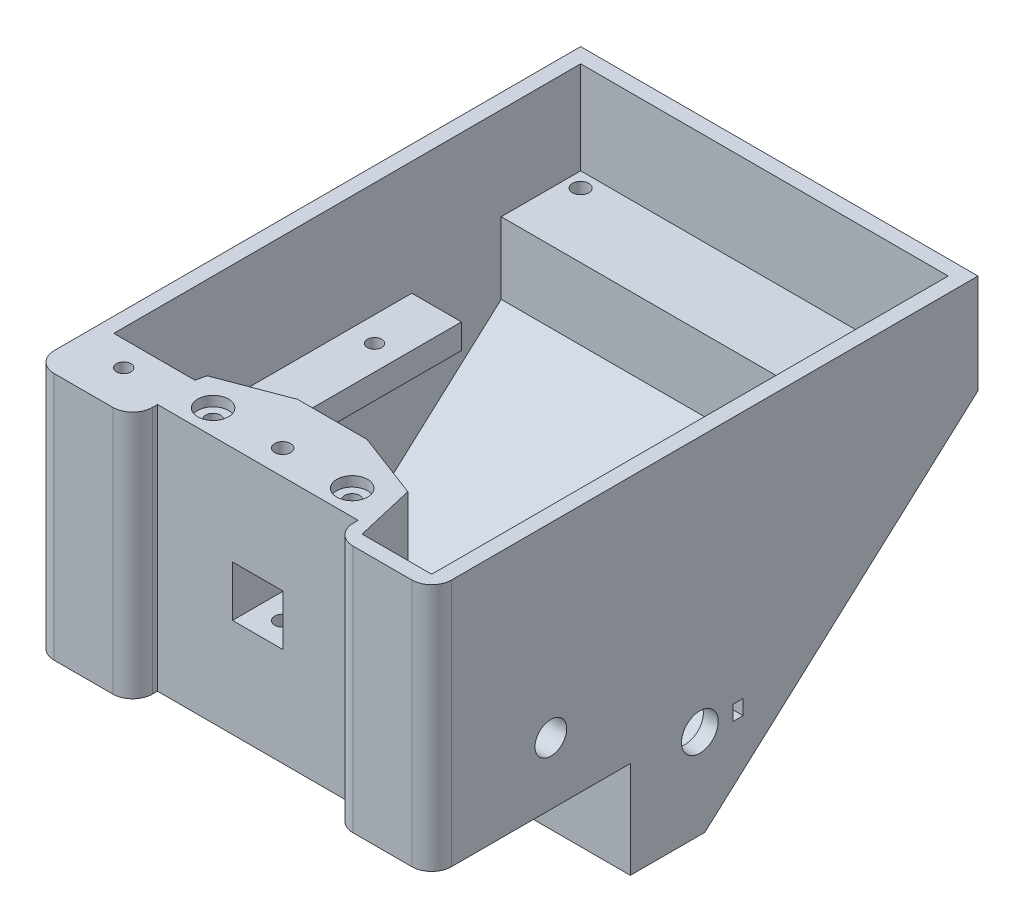
from build123d import *

# Parameters (mm, degrees)
BOSS_EXTRUDE1_DEPTH = 80
SHELL1_T            = -3
SKETCH3_W           = 46
SKETCH3_H           = 47
BOSS_EXTRUDE2_DEPTH = 17
SKETCH4_W           = 10.2
SKETCH4_H           = 10.2
CUT_EXTRUDE1_DEPTH  = 20
SKETCH6_W           = 15
SKETCH6_H           = 12.8
CUT_EXTRUDE2_DEPTH  = 3
SKETCH7_W           = 40.4
SKETCH7_H           = 50
CUT_EXTRUDE3_DEPTH  = 5
FILLET1_R           = 4
CUT_EXTRUDE7_DEPTH  = 47
SKETCH13_R          = 1.5
CUT_EXTRUDE8_DEPTH  = 25
SKETCH14_R          = 3.1
CUT_EXTRUDE9_DEPTH  = 2
SKETCH17_W          = 45
SKETCH17_H          = 5
BOSS_EXTRUDE5_DEPTH = 74
CUT_EXTRUDE10_REACH = 48.51
SKETCH18_W          = 54
SKETCH18_H          = 45
CUT_EXTRUDE11_REACH = 48.51
SKETCH19_R          = 1.45
BOSS_EXTRUDE6_DEPTH = 47
SKETCH22_R          = 1.45
CUT_EXTRUDE12_DEPTH = 70.509632224
CUT_EXTRUDE13_REACH = 82
SKETCH24_R          = 3.7
SKETCH24_W          = 2
SKETCH24_H          = 3
BOSS_EXTRUDE7_DEPTH = 74
SKETCH27_R          = 1.65
CUT_EXTRUDE14_DEPTH = 10
CUT_EXTRUDE15_START = -3
CUT_EXTRUDE15_DEPTH = 32
CUT_EXTRUDE16_DEPTH = 30
BOSS_EXTRUDE8_DEPTH = 20
SKETCH31_R          = 1.5
CUT_EXTRUDE17_DEPTH = 43.509632224
CUT_EXTRUDE18_DEPTH = 15
CUT_EXTRUDE19_REACH = 48.51
SKETCH33_W          = 10
SKETCH33_H          = 5
SKETCH34_R          = 1.6
CUT_EXTRUDE20_DEPTH = 70.509632224
CUT_EXTRUDE22_DEPTH = 14
CUT_EXTRUDE23_REACH = 82
SKETCH37_R          = 3.2
SKETCH38_W          = 10
SKETCH38_H          = 18.980735551
SKETCH38_R          = 3.2
BOSS_EXTRUDE9_DEPTH = 3


with BuildPart() as part:
    # Sketch2 → Boss-Extrude1 (new body)
    with BuildSketch(Plane(origin=(0, 0, 0), x_dir=(0, 0, -1), z_dir=(1, 0, 0))):
        Polygon((-27.320490368, 20.998248687), (-27.320490368, -29.001751313), (12.679509632, -29.001751313), (12.679509632, -48.511383538), (27.679509632, -48.511383538), (82.679509632, 0.998248687), (82.679509632, 20.998248687), align=None)
    extrude(amount=BOSS_EXTRUDE1_DEPTH)

    # Shell1
    shell1_openings = [part.faces().sort_by_distance(p)[0] for p in [
        (40, 20.998248687, -27.679509632),
    ]]
    offset(amount=SHELL1_T, openings=shell1_openings, kind=Kind.INTERSECTION)

    # Sketch3 → Boss-Extrude2 (add)
    with BuildSketch(Plane(origin=(0, 0, 24.320490368), x_dir=(-1, 0, 0), z_dir=(0, 0, -1))):
        with Locations((-40, -2.501751313)):
            Rectangle(SKETCH3_W, SKETCH3_H)
    extrude(amount=BOSS_EXTRUDE2_DEPTH)

    # Sketch4 → Cut-Extrude1 (cut)
    with BuildSketch(Plane.XY.offset(27.320490368)):
        with Locations((40, -4.001751313)):
            Rectangle(SKETCH4_W, SKETCH4_H)
    extrude(amount=-CUT_EXTRUDE1_DEPTH, mode=Mode.SUBTRACT)

    # Sketch6 → Cut-Extrude2 (cut)
    with BuildSketch(Plane.XZ.offset(29.001751313)):
        with Locations((40, 0.920490368)):
            Rectangle(SKETCH6_W, SKETCH6_H)
    extrude(amount=-CUT_EXTRUDE2_DEPTH, mode=Mode.SUBTRACT)

    # Sketch7 → Cut-Extrude3 (cut)
    with BuildSketch(Plane.XY.offset(27.320490368)):
        with Locations((40, -4.001751313)):
            Rectangle(SKETCH7_W, SKETCH7_H)
    extrude(amount=-CUT_EXTRUDE3_DEPTH, mode=Mode.SUBTRACT)

    # Fillet1
    fillet1_edges = [part.edges().sort_by_distance(p)[0] for p in [
        (80, -4.001751313, 27.320490368),
        (19.8, -4.001751313, 27.320490368),
        (0, -4.001751313, 27.320490368),
        (60.2, -4.001751313, 27.320490368),
    ]]
    fillet(fillet1_edges, radius=FILLET1_R)

    # Sketch12 → Cut-Extrude7 (cut)
    with BuildSketch(Plane(origin=(0, 20.998248687, 0), x_dir=(1, 0, 0), z_dir=(0, 1, 0))):
        Polygon((33, -7.320490368), (19.8, -12.320490368), (17, -24.320490368), (17, -7.320490368), align=None)
        Polygon((47, -7.320490368), (63, -7.320490368), (63, -24.320490368), (60.2, -12.320490368), align=None)
    extrude(amount=-CUT_EXTRUDE7_DEPTH, mode=Mode.SUBTRACT)

    # Sketch13 → Cut-Extrude8 (cut)
    with BuildSketch(Plane(origin=(0, 20.998248687, 0), x_dir=(1, 0, 0), z_dir=(0, 1, 0))):
        with Locations(Location((26, -17.320490368, 0), (0, 0, 270))):  # turned: the seam where the file's is
            Circle(SKETCH13_R)
        with Locations(Location((54, -17.320490368, 0), (0, 0, 270))):  # turned: the seam where the file's is
            Circle(SKETCH13_R)
    extrude(amount=-CUT_EXTRUDE8_DEPTH, mode=Mode.SUBTRACT)

    # Sketch14 → Cut-Extrude9 (cut)
    with BuildSketch(Plane(origin=(0, 20.998248687, 0), x_dir=(1, 0, 0), z_dir=(0, 1, 0))):
        with Locations(Location((26, -17.320490368, 0), (0, 0, 270))):  # turned: the seam where the file's is
            Circle(SKETCH14_R)
        with Locations(Location((54, -17.320490368, 0), (0, 0, 270))):  # turned: the seam where the file's is
            Circle(SKETCH14_R)
    extrude(amount=-CUT_EXTRUDE9_DEPTH, mode=Mode.SUBTRACT)

    # Sketch17 → Boss-Extrude5 (add)
    with BuildSketch(Plane.ZY.offset(-77)):
        with Locations((-23.179509632, -4.501751313)):
            Rectangle(SKETCH17_W, SKETCH17_H)
    extrude(amount=BOSS_EXTRUDE5_DEPTH)

    # Sketch18 → Cut-Extrude10 (cut, up to next)
    with BuildSketch(Plane(origin=(0, -2.001751313, 0), x_dir=(1, 0, 0), z_dir=(0, 1, 0)), mode=Mode.PRIVATE) as cut_extrude10_sk1:
        with Locations((40, 23.179509632)):
            Rectangle(SKETCH18_W, SKETCH18_H)
    cut_extrude10_tool1 = extrude(cut_extrude10_sk1.sketch, amount=-CUT_EXTRUDE10_REACH, mode=Mode.PRIVATE) & part.part
    add(cut_extrude10_tool1.solids().sort_by_distance((40, -2.001751, -23.17951))[0], mode=Mode.SUBTRACT)

    # Sketch19 → Cut-Extrude11 (cut, up to next)
    with BuildSketch(Plane(origin=(0, -2.001751313, 0), x_dir=(1, 0, 0), z_dir=(0, 1, 0)), mode=Mode.PRIVATE) as cut_extrude11_sk1:
        with Locations(Location((72, 37.179509632, 0), (0, 0, 270))):  # turned: the seam where the file's is
            Circle(SKETCH19_R)
    cut_extrude11_tool1 = extrude(cut_extrude11_sk1.sketch, amount=-CUT_EXTRUDE11_REACH, mode=Mode.PRIVATE) & part.part
    add(cut_extrude11_tool1.solids().sort_by_distance((72, -2.001751, -37.17951))[0], mode=Mode.SUBTRACT)
    # Sketch19 → Cut-Extrude11 (cut, up to next)
    with BuildSketch(Plane(origin=(0, -2.001751313, 0), x_dir=(1, 0, 0), z_dir=(0, 1, 0)), mode=Mode.PRIVATE) as cut_extrude11_sk2:
        with Locations(Location((72, 6.179509632, 0), (0, 0, 270))):  # turned: the seam where the file's is
            Circle(SKETCH19_R)
    cut_extrude11_tool2 = extrude(cut_extrude11_sk2.sketch, amount=-CUT_EXTRUDE11_REACH, mode=Mode.PRIVATE) & part.part
    add(cut_extrude11_tool2.solids().sort_by_distance((72, -2.001751, -6.17951))[0], mode=Mode.SUBTRACT)
    # Sketch19 → Cut-Extrude11 (cut, up to next)
    with BuildSketch(Plane(origin=(0, -2.001751313, 0), x_dir=(1, 0, 0), z_dir=(0, 1, 0)), mode=Mode.PRIVATE) as cut_extrude11_sk3:
        with Locations(Location((8, 33.179509632, 0), (0, 0, 270))):  # turned: the seam where the file's is
            Circle(SKETCH19_R)
    cut_extrude11_tool3 = extrude(cut_extrude11_sk3.sketch, amount=-CUT_EXTRUDE11_REACH, mode=Mode.PRIVATE) & part.part
    add(cut_extrude11_tool3.solids().sort_by_distance((8, -2.001751, -33.17951))[0], mode=Mode.SUBTRACT)
    # Sketch19 → Cut-Extrude11 (cut, up to next)
    with BuildSketch(Plane(origin=(0, -2.001751313, 0), x_dir=(1, 0, 0), z_dir=(0, 1, 0)), mode=Mode.PRIVATE) as cut_extrude11_sk4:
        with Locations(Location((8, 6.179509632, 0), (0, 0, 270))):  # turned: the seam where the file's is
            Circle(SKETCH19_R)
    cut_extrude11_tool4 = extrude(cut_extrude11_sk4.sketch, amount=-CUT_EXTRUDE11_REACH, mode=Mode.PRIVATE) & part.part
    add(cut_extrude11_tool4.solids().sort_by_distance((8, -2.001751, -6.17951))[0], mode=Mode.SUBTRACT)

    # Sketch21 → Boss-Extrude6 (add)
    with BuildSketch(Plane(origin=(0, -26.001751313, 0), x_dir=(1, 0, 0), z_dir=(0, 1, 0))):
        Polygon((3, -24.320490368), (3, -14.320490368), (19.333333333, -14.320490368), (17, -24.320490368), align=None)
    extrude(amount=BOSS_EXTRUDE6_DEPTH)

    # Sketch22 → Cut-Extrude12 (cut, through all)
    with BuildSketch(Plane(origin=(0, 20.998248687, 0), x_dir=(1, 0, 0), z_dir=(0, 1, 0))):
        with Locations(Location((10, -19.320490368, 0), (0, 0, 270))):  # turned: the seam where the file's is
            Circle(SKETCH22_R)
    extrude(amount=-CUT_EXTRUDE12_DEPTH, mode=Mode.SUBTRACT)

    # Sketch24 → Cut-Extrude13 (cut, up to next)
    with BuildSketch(Plane(origin=(80, 0, 0), x_dir=(0, 0, -1), z_dir=(1, 0, 0)), mode=Mode.PRIVATE) as cut_extrude13_sk1:
        with Locations((26.679509632, -30.511383538)):
            Circle(SKETCH24_R)
    cut_extrude13_tool1 = extrude(cut_extrude13_sk1.sketch, amount=-CUT_EXTRUDE13_REACH, mode=Mode.PRIVATE) & part.part
    add(cut_extrude13_tool1.solids().sort_by_distance((80, -30.511384, -26.67951))[0], mode=Mode.SUBTRACT)
    # Sketch24 → Cut-Extrude13 (cut, up to next)
    with BuildSketch(Plane(origin=(80, 0, 0), x_dir=(0, 0, -1), z_dir=(1, 0, 0)), mode=Mode.PRIVATE) as cut_extrude13_sk2:
        with Locations((34.379509632, -30.511383538)):
            Rectangle(SKETCH24_W, SKETCH24_H)
    cut_extrude13_tool2 = extrude(cut_extrude13_sk2.sketch, amount=-CUT_EXTRUDE13_REACH, mode=Mode.PRIVATE) & part.part
    add(cut_extrude13_tool2.solids().sort_by_distance((80, -30.511384, -34.37951))[0], mode=Mode.SUBTRACT)

    # Sketch26 → Boss-Extrude7 (add)
    with BuildSketch(Plane(origin=(3, 0, 0), x_dir=(0, 0, -1), z_dir=(1, 0, 0))):
        Polygon((79.679509632, 2.334161996), (63.679509632, 2.334161996), (63.679509632, -12.068640106), align=None)
    extrude(amount=BOSS_EXTRUDE7_DEPTH)

    # Sketch27 → Cut-Extrude14 (cut)
    with BuildSketch(Plane(origin=(0, 2.334161996, 0), x_dir=(1, 0, 0), z_dir=(0, 1, 0))):
        with Locations(Location((6, 76.679509632, 0), (0, 0, 270))):  # turned: the seam where the file's is
            Circle(SKETCH27_R)
        with Locations(Location((74, 76.679509632, 0), (0, 0, 270))):  # turned: the seam where the file's is
            Circle(SKETCH27_R)
    extrude(amount=-CUT_EXTRUDE14_DEPTH, mode=Mode.SUBTRACT)

    # Sketch28 → Cut-Extrude15 (cut)
    with BuildSketch(Plane(origin=(0, 2.334161996, 0), x_dir=(1, 0, 0), z_dir=(0, 1, 0)).offset(CUT_EXTRUDE15_START)):
        Polygon((74, 79.929509632), (71.185417438, 78.304509632), (71.185417438, 75.054509632), (74, 73.429509632), (76.814582562, 75.054509632), (76.814582562, 78.304509632), align=None)
        Polygon((6, 73.429509632), (8.814582562, 75.054509632), (8.814582562, 78.304509632), (6, 79.929509632), (3.185417438, 78.304509632), (3.185417438, 75.054509632), align=None)
    extrude(amount=-CUT_EXTRUDE15_DEPTH, mode=Mode.SUBTRACT)

    # Sketch29 → Cut-Extrude16 (cut)
    with BuildSketch(Plane.XZ.offset(29.001751313)):
        Polygon((7.185417438, 17.695490368), (10, 16.070490368), (12.814582562, 17.695490368), (12.814582562, 20.945490368), (10, 22.570490368), (7.185417438, 20.945490368), align=None)
    extrude(amount=-CUT_EXTRUDE16_DEPTH, mode=Mode.SUBTRACT)

    # Sketch30 → Boss-Extrude8 (add)
    with BuildSketch(Plane(origin=(0, -26.001751313, 0), x_dir=(1, 0, 0), z_dir=(0, 1, 0))):
        Polygon((77, -24.320490368), (63, -24.320490368), (60.2, -12.320490368), (77, -12.320490368), align=None)
    extrude(amount=BOSS_EXTRUDE8_DEPTH)

    # Sketch31 → Cut-Extrude17 (cut, through all)
    with BuildSketch(Plane(origin=(0, -6.001751313, 0), x_dir=(1, 0, 0), z_dir=(0, 1, 0))):
        with Locations(Location((72, -21.320490368, 0), (0, 0, 270))):  # turned: the seam where the file's is
            Circle(SKETCH31_R)
    extrude(amount=-CUT_EXTRUDE17_DEPTH, mode=Mode.SUBTRACT)

    # Sketch32 → Cut-Extrude18 (cut)
    with BuildSketch(Plane.XZ.offset(29.001751313)):
        Polygon((72, 24.570490368), (69.185417438, 22.945490368), (69.185417438, 19.695490368), (72, 18.070490368), (74.814582562, 19.695490368), (74.814582562, 22.945490368), align=None)
    extrude(amount=-CUT_EXTRUDE18_DEPTH, mode=Mode.SUBTRACT)

    # Sketch33 → Cut-Extrude19 (cut, up to next)
    with BuildSketch(Plane(origin=(0, -2.001751313, 0), x_dir=(1, 0, 0), z_dir=(0, 1, 0)), mode=Mode.PRIVATE) as cut_extrude19_sk1:
        with Locations((72, 43.179509632)):
            Rectangle(SKETCH33_W, SKETCH33_H)
    cut_extrude19_tool1 = extrude(cut_extrude19_sk1.sketch, amount=-CUT_EXTRUDE19_REACH, mode=Mode.PRIVATE) & part.part
    add(cut_extrude19_tool1.solids().sort_by_distance((72, -2.001751, -43.17951))[0], mode=Mode.SUBTRACT)

    # Sketch34 → Cut-Extrude20 (cut, through all)
    with BuildSketch(Plane(origin=(0, 20.998248687, 0), x_dir=(1, 0, 0), z_dir=(0, 1, 0))):
        with Locations(Location((40, -17.320490368, 0), (0, 0, 270))):  # turned: the seam where the file's is
            Circle(SKETCH34_R)
    extrude(amount=-CUT_EXTRUDE20_DEPTH, mode=Mode.SUBTRACT)

    # Sketch36 → Cut-Extrude22 (cut)
    with BuildSketch(Plane.XZ.offset(29.001751313)):
        Polygon((38.375, 20.13507293), (36.75, 17.320490368), (38.375, 14.505907805), (41.625, 14.505907805), (43.25, 17.320490368), (41.625, 20.13507293), align=None)
    extrude(amount=-CUT_EXTRUDE22_DEPTH, mode=Mode.SUBTRACT)

    # Sketch37 → Cut-Extrude23 (cut, up to next)
    with BuildSketch(Plane(origin=(80, 0, 0), x_dir=(0, 0, -1), z_dir=(1, 0, 0)), mode=Mode.PRIVATE) as cut_extrude23_sk1:
        with Locations((-3.320490368, -16.511383538)):
            Circle(SKETCH37_R)
    cut_extrude23_tool1 = extrude(cut_extrude23_sk1.sketch, amount=-CUT_EXTRUDE23_REACH, mode=Mode.PRIVATE) & part.part
    add(cut_extrude23_tool1.solids().sort_by_distance((80, -16.511384, 3.32049))[0], mode=Mode.SUBTRACT)

    # Sketch38 → Boss-Extrude9 (add)
    with BuildSketch(Plane.ZY.offset(-77)):
        with Locations((3.320490368, -16.511383538)):
            Rectangle(SKETCH38_W, SKETCH38_H)
        with Locations(Location((3.320490368, -16.511383538, 0), (0, 0, 180))):  # turned: the seam where the file's is
            Circle(SKETCH38_R, mode=Mode.SUBTRACT)
    extrude(amount=BOSS_EXTRUDE9_DEPTH)


solid = part.part
